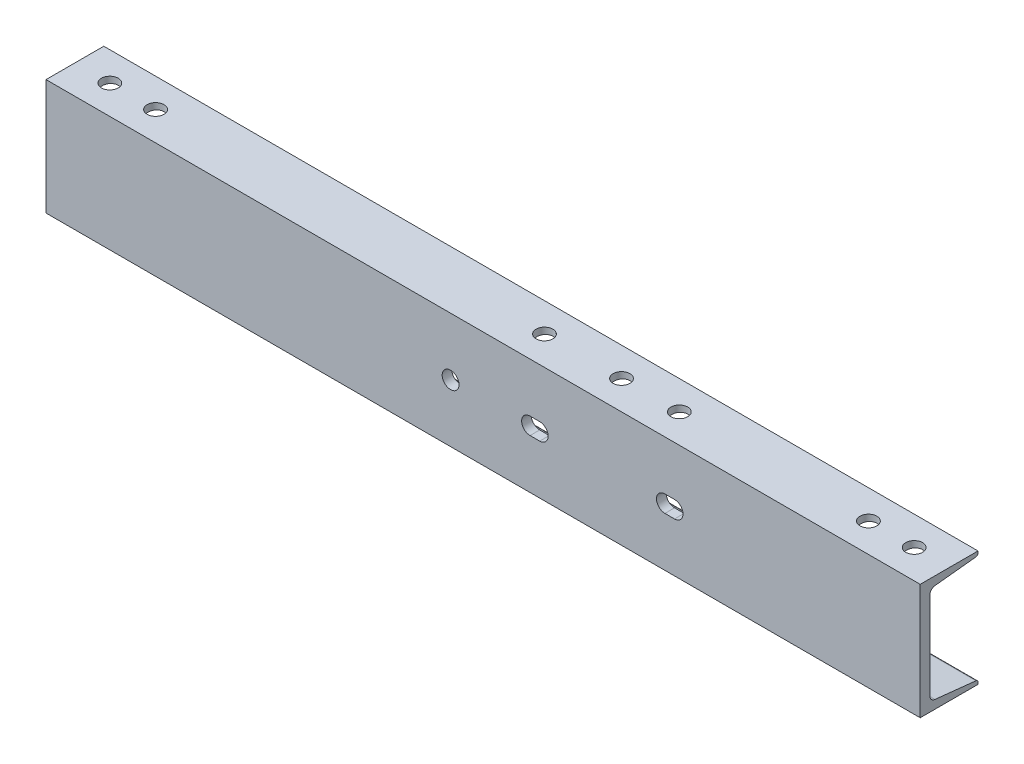
from build123d import *

# Parameters (mm, degrees)
BOSS_EXTRUDE1_DEPTH = 576.2625
SKETCH5_R           = 11.1125
CUT_EXTRUDE3_DEPTH  = 152.4
SKETCH6_R           = 11.1125
CUT_EXTRUDE4_DEPTH  = 13.7


with BuildPart() as part:
    # Sketch1 → Boss-Extrude1 (new body, symmetric)
    with BuildSketch(Plane(origin=(0, 0, 0), x_dir=(0, 0, -1), z_dir=(1, 0, 0))):
        with BuildLine():
            Line((-48.8061, -76.2), (-48.8061, 76.2))
            Line((-48.8061, 76.2), (27.3939, 76.2))
            Line((27.3939, 76.2), (27.3939, 73.710744653))
            ThreePointArc((27.3939, 73.710744653), (26.61173954, 71.672050174), (24.666685315, 70.679672107))
            Line((24.666685315, 70.679672107), (-29.288063286, 64.969518115))
            ThreePointArc((-29.288063286, 64.969518115), (-34.150698849, 62.488572947), (-36.1061, 57.391836749))
            Line((-36.1061, 57.391836749), (-36.1061, -57.391836749))
            ThreePointArc((-36.1061, -57.391836749), (-34.150698849, -62.488572947), (-29.288063286, -64.969518115))
            Line((-29.288063286, -64.969518115), (24.666685315, -70.679672107))
            ThreePointArc((24.666685315, -70.679672107), (26.61173954, -71.672050174), (27.3939, -73.710744653))
            Line((27.3939, -73.710744653), (27.3939, -76.2))
            Line((27.3939, -76.2), (-48.8061, -76.2))
        make_face()
    extrude(amount=BOSS_EXTRUDE1_DEPTH, both=True)

    # Sketch5 → Cut-Extrude3 (cut)
    with BuildSketch(Plane.XZ.offset(76.2)):
        with Locations((530.225, 10.7061)):
            Circle(SKETCH5_R)
        with Locations((469.9, 10.7061)):
            Circle(SKETCH5_R)
        with Locations((220.599, 10.7061)):
            Circle(SKETCH5_R)
        with Locations((42.799, 10.7061)):
            Circle(SKETCH5_R)
        with Locations((144.399, 10.7061)):
            Circle(SKETCH5_R)
        with Locations((-530.225, 10.7061)):
            Circle(SKETCH5_R)
        with Locations((-469.9, 10.7061)):
            Circle(SKETCH5_R)
    extrude(amount=-CUT_EXTRUDE3_DEPTH, mode=Mode.SUBTRACT)

    # Sketch6 → Cut-Extrude4 (cut, through all)
    with BuildSketch(Plane(origin=(0, 0, 36.1061), x_dir=(-1, 0, 0), z_dir=(0, 0, -1))):
        with Locations((42.8625, 0)):
            Circle(SKETCH6_R)
        with BuildLine():
            Line((-61.9125, -11.1125), (-74.6125, -11.1125))
            ThreePointArc((-74.6125, -11.1125), (-85.725, 0), (-74.6125, 11.1125))
            Line((-74.6125, 11.1125), (-61.9125, 11.1125))
            ThreePointArc((-61.9125, 11.1125), (-50.8, 0), (-61.9125, -11.1125))
        make_face()
        with BuildLine():
            Line((-239.7125, -11.1125), (-252.4125, -11.1125))
            ThreePointArc((-252.4125, -11.1125), (-263.525, 0), (-252.4125, 11.1125))
            Line((-252.4125, 11.1125), (-239.7125, 11.1125))
            ThreePointArc((-239.7125, 11.1125), (-228.6, 0), (-239.7125, -11.1125))
        make_face()
    extrude(amount=-CUT_EXTRUDE4_DEPTH, mode=Mode.SUBTRACT)


solid = part.part
